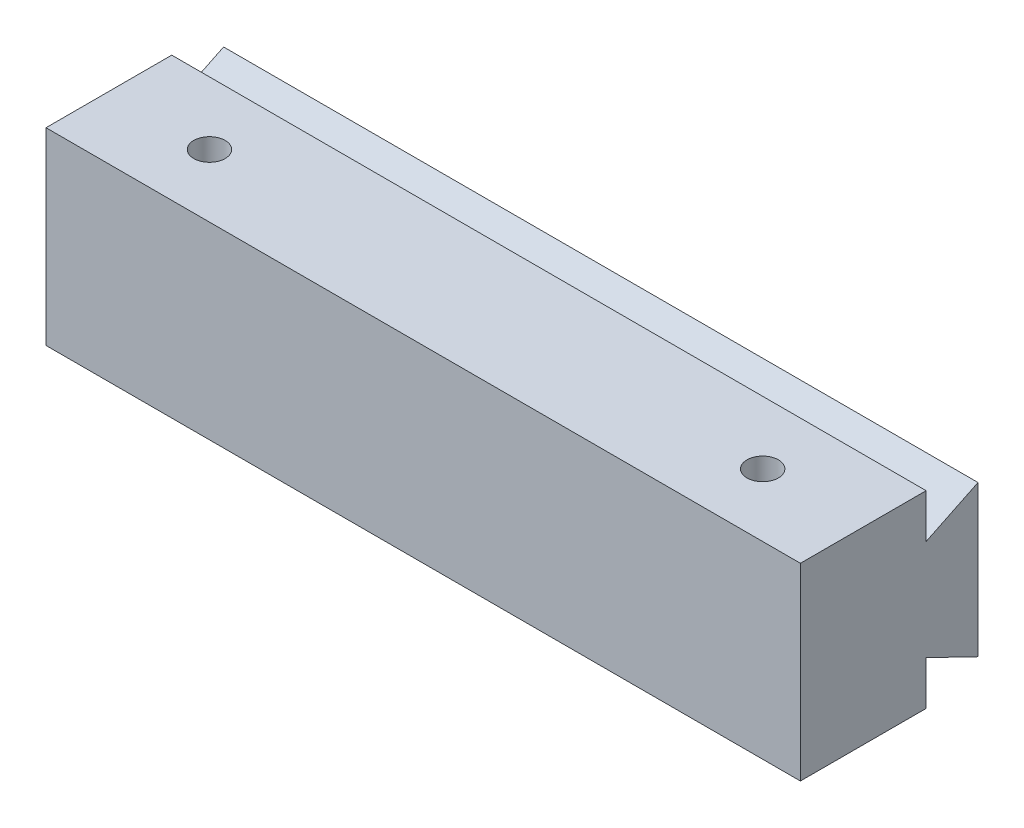
from build123d import *

# Parameters (mm, degrees)
SKETCH1_W               = 60
SKETCH1_H               = 15
BOSS_EXTRUDE1_DEPTH     = 10
BOSS_EXTRUDE2_DEPTH     = 60
SKETCH3_R               = 1.25
CUT_EXTRUDE1_DEPTH      = 1
CUT_EXTRUDE1_DEPTH_BACK = 16


with BuildPart() as part:
    # Sketch1 → Boss-Extrude1 (new body)
    with BuildSketch(Plane.XY):
        Rectangle(SKETCH1_W, SKETCH1_H)
    extrude(amount=BOSS_EXTRUDE1_DEPTH)

    # Sketch2 → Boss-Extrude2 (add)
    with BuildSketch(Plane(origin=(30, 0, 0), x_dir=(0, 0, -1), z_dir=(1, 0, 0))):
        Polygon((0, 4), (4.124819933, 6), (4.124819933, -6), (0, -4), align=None)
    extrude(amount=-BOSS_EXTRUDE2_DEPTH)

    # Sketch3 → Cut-Extrude1 (cut, two sides)
    with BuildSketch(Plane(origin=(0, 7.5, 0), x_dir=(1, 0, 0), z_dir=(0, 1, 0))) as cut_extrude1_sk:
        with Locations((-22, -5)):
            Circle(SKETCH3_R)
        with Locations((22, -5)):
            Circle(SKETCH3_R)
    extrude(amount=CUT_EXTRUDE1_DEPTH, mode=Mode.SUBTRACT)
    extrude(cut_extrude1_sk.sketch, amount=-CUT_EXTRUDE1_DEPTH_BACK, mode=Mode.SUBTRACT)


solid = part.part
